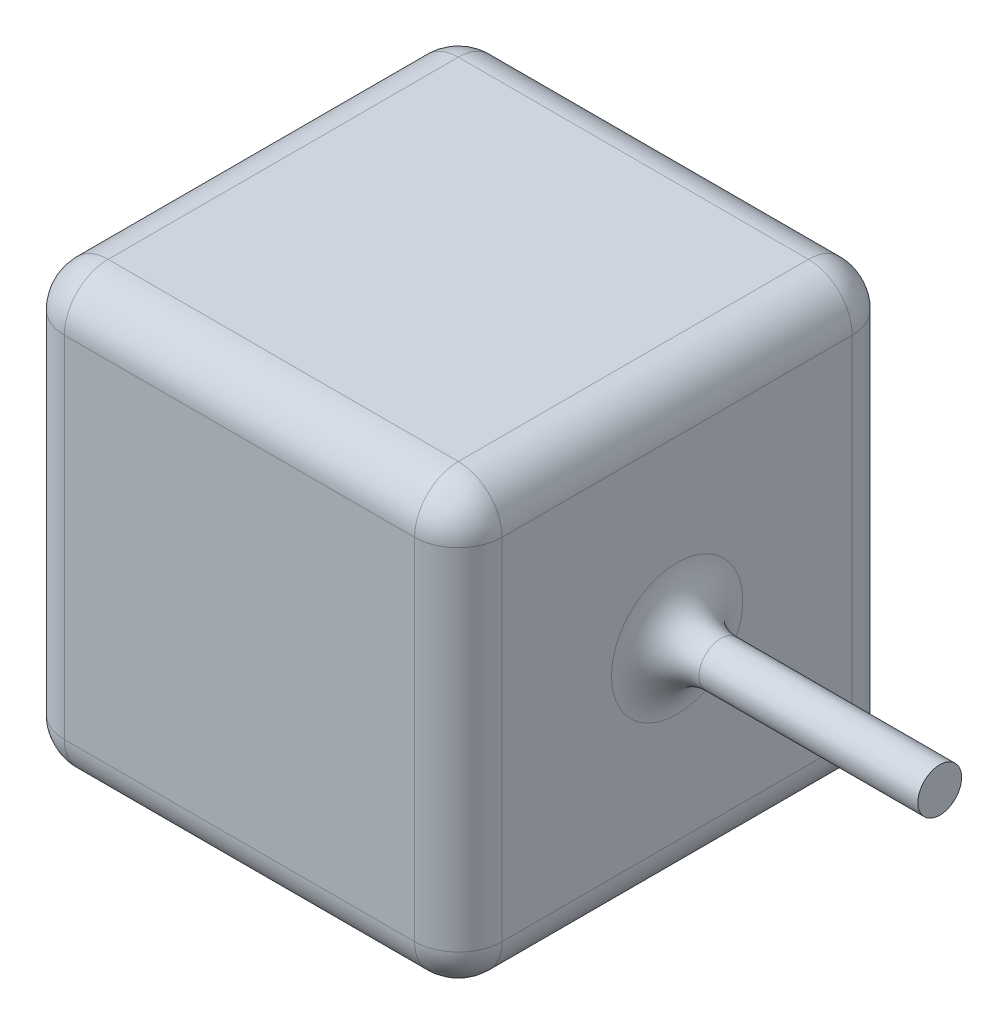
from build123d import *

# Parameters (mm, degrees)
SKETCH2_W           = 100
SKETCH2_H           = 100
BOSS_EXTRUDE1_DEPTH = 100
SKETCH3_R           = 5
BOSS_EXTRUDE2_DEPTH = 60
FILLET5_R           = 10


with BuildPart() as part:
    # Sketch2 → Boss-Extrude1 (new body)
    with BuildSketch(Plane(origin=(0, 0, 0), x_dir=(1, 0, 0), z_dir=(0, 1, 0))):
        with Locations((50, 50)):
            Rectangle(SKETCH2_W, SKETCH2_H)
    extrude(amount=BOSS_EXTRUDE1_DEPTH)

    # Sketch3 → Boss-Extrude2 (add)
    with BuildSketch(Plane(origin=(100, 0, 0), x_dir=(0, 0, -1), z_dir=(1, 0, 0))):
        with Locations((50, 50)):
            Circle(SKETCH3_R)
    extrude(amount=BOSS_EXTRUDE2_DEPTH)

    # Fillet5
    fillet5_edges = [part.edges().sort_by_distance(p)[0] for p in [
        (100, 100, -50),
        (50, 100, -100),
        (100, 50, -45),
        (0, 100, -50),
        (50, 0, -100),
        (100, 0, -50),
        (50, 0, 0),
        (0, 0, -50),
        (50, 100, 0),
        (0, 50, -100),
        (100, 50, -100),
        (100, 50, 0),
        (0, 50, 0),
    ]]
    fillet(fillet5_edges, radius=FILLET5_R)


solid = part.part
